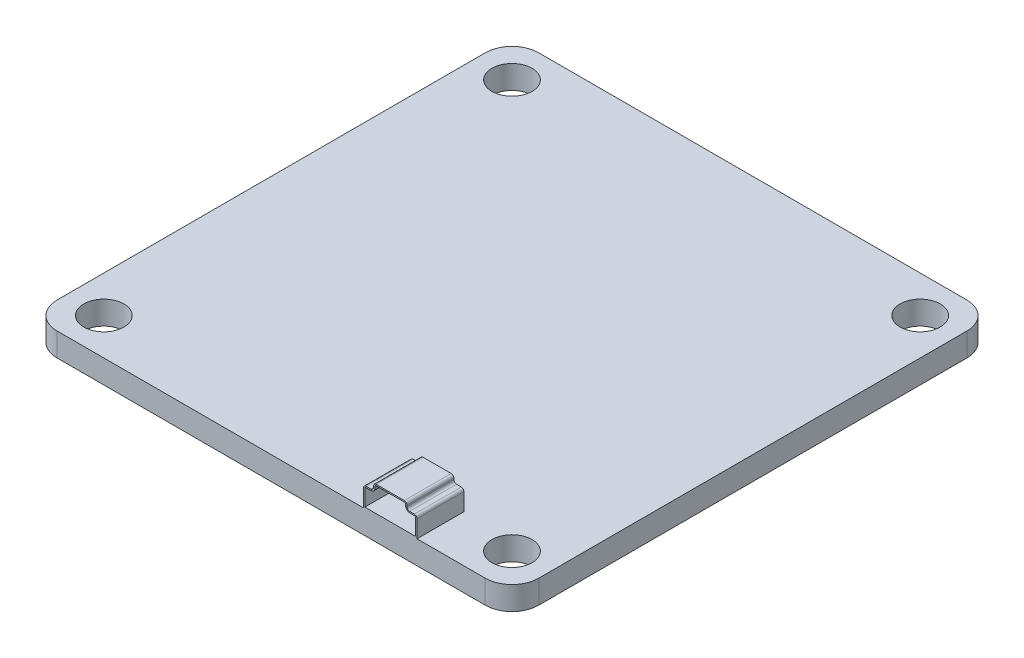
from build123d import *

# Parameters (mm, degrees)
SKETCH1_R           = 1.5
BOSS_EXTRUDE3_DEPTH = 1.75
BOSS_EXTRUDE4_DEPTH = 3.00210529
BOSS_EXTRUDE5_DEPTH = 0.5


with BuildPart() as part:
    # Sketch1 → Boss-Extrude3 (new body)
    with BuildSketch(Plane(origin=(0, 0, 0), x_dir=(1, 0, 0), z_dir=(0, 1, 0))):
        with BuildLine():
            Line((16, -18), (-16, -18))
            ThreePointArc((-16, -18), (-17.414213562, -17.414213562), (-18, -16))
            Line((-18, -16), (-18, 16))
            ThreePointArc((-18, 16), (-17.414213562, 17.414213562), (-16, 18))
            Line((-16, 18), (16, 18))
            ThreePointArc((16, 18), (17.414213562, 17.414213562), (18, 16))
            Line((18, 16), (18, -16))
            ThreePointArc((18, -16), (17.414213562, -17.414213562), (16, -18))
        make_face()
        with Locations((-15.25, 15.25)):
            Circle(SKETCH1_R, mode=Mode.SUBTRACT)
        with Locations((15.25, 15.25)):
            Circle(SKETCH1_R, mode=Mode.SUBTRACT)
        with Locations((15.25, -15.25)):
            Circle(SKETCH1_R, mode=Mode.SUBTRACT)
        with Locations((-15.25, -15.25)):
            Circle(SKETCH1_R, mode=Mode.SUBTRACT)
    extrude(amount=BOSS_EXTRUDE3_DEPTH)

    # Sketch6 → Boss-Extrude4 (add)
    with BuildSketch(Plane(origin=(-4.326463131, 0, 18), x_dir=(1, 0, 0), z_dir=(0, 0, 1))):
        with BuildLine():
            Line((11.230523664, 1.75), (15.230523664, 1.75))
            Line((15.230523664, 1.75), (15.230523664, 3.050219677))
            ThreePointArc((15.230523664, 3.050219677), (15.17194502, 3.191641033), (15.030523664, 3.250219677))
            Line((15.030523664, 3.250219677), (14.680523664, 3.250219677))
            ThreePointArc((14.680523664, 3.250219677), (14.539102307, 3.308798321), (14.480523664, 3.450219677))
            Line((14.480523664, 3.450219677), (14.480523664, 3.55))
            ThreePointArc((14.480523664, 3.55), (14.42194502, 3.691421356), (14.280523664, 3.75))
            Line((14.280523664, 3.75), (12.180523664, 3.75))
            ThreePointArc((12.180523664, 3.75), (12.039102307, 3.691421356), (11.980523664, 3.55))
            Line((11.980523664, 3.55), (11.980523664, 3.450219677))
            ThreePointArc((11.980523664, 3.450219677), (11.92194502, 3.308798321), (11.780523664, 3.250219677))
            Line((11.780523664, 3.250219677), (11.430523664, 3.250219677))
            ThreePointArc((11.430523664, 3.250219677), (11.289102307, 3.191641033), (11.230523664, 3.050219677))
            Line((11.230523664, 3.050219677), (11.230523664, 1.75))
        make_face()
        with BuildLine():
            Line((12.180523664, 3.65), (14.280523664, 3.65))
            ThreePointArc((14.280523664, 3.65), (14.351234342, 3.620710678), (14.380523664, 3.55))
            Line((14.380523664, 3.55), (14.380523664, 3.450219677))
            ThreePointArc((14.380523664, 3.450219677), (14.468391629, 3.238087642), (14.680523664, 3.150219677))
            Line((14.680523664, 3.150219677), (15.030523664, 3.150219677))
            ThreePointArc((15.030523664, 3.150219677), (15.101234342, 3.120930355), (15.130523664, 3.050219677))
            Line((15.130523664, 3.050219677), (15.130523664, 1.85))
            Line((15.130523664, 1.85), (11.330523664, 1.85))
            Line((11.330523664, 1.85), (11.330523664, 3.050219677))
            ThreePointArc((11.330523664, 3.050219677), (11.359812985, 3.120930355), (11.430523664, 3.150219677))
            Line((11.430523664, 3.150219677), (11.780523664, 3.150219677))
            ThreePointArc((11.780523664, 3.150219677), (11.992655698, 3.238087642), (12.080523664, 3.450219677))
            Line((12.080523664, 3.450219677), (12.080523664, 3.55))
            ThreePointArc((12.080523664, 3.55), (12.109812985, 3.620710678), (12.180523664, 3.65))
        make_face(mode=Mode.SUBTRACT)
    extrude(amount=-BOSS_EXTRUDE4_DEPTH)

    # Sketch7 → Boss-Extrude5 (add)
    with BuildSketch(Plane(origin=(0, 0, 14.99789471), x_dir=(-1, 0, 0), z_dir=(0, 0, -1))):
        with BuildLine():
            Line((-6.904060533, 1.75), (-6.904060533, 3.050219677))
            ThreePointArc((-6.904060533, 3.050219677), (-6.962639176, 3.191641033), (-7.104060533, 3.250219677))
            Line((-7.104060533, 3.250219677), (-7.454060533, 3.250219677))
            ThreePointArc((-7.454060533, 3.250219677), (-7.595481889, 3.308798321), (-7.654060533, 3.450219677))
            Line((-7.654060533, 3.450219677), (-7.654060533, 3.55))
            ThreePointArc((-7.654060533, 3.55), (-7.712639176, 3.691421356), (-7.854060533, 3.75))
            Line((-7.854060533, 3.75), (-9.954060533, 3.75))
            ThreePointArc((-9.954060533, 3.75), (-10.095481889, 3.691421356), (-10.154060533, 3.55))
            Line((-10.154060533, 3.55), (-10.154060533, 3.450219677))
            ThreePointArc((-10.154060533, 3.450219677), (-10.212639176, 3.308798321), (-10.354060533, 3.250219677))
            Line((-10.354060533, 3.250219677), (-10.704060533, 3.250219677))
            ThreePointArc((-10.704060533, 3.250219677), (-10.845481889, 3.191641033), (-10.904060533, 3.050219677))
            Line((-10.904060533, 3.050219677), (-10.904060533, 1.75))
            Line((-10.904060533, 1.75), (-6.904060533, 1.75))
        make_face()
    extrude(amount=BOSS_EXTRUDE5_DEPTH)


solid = part.part
